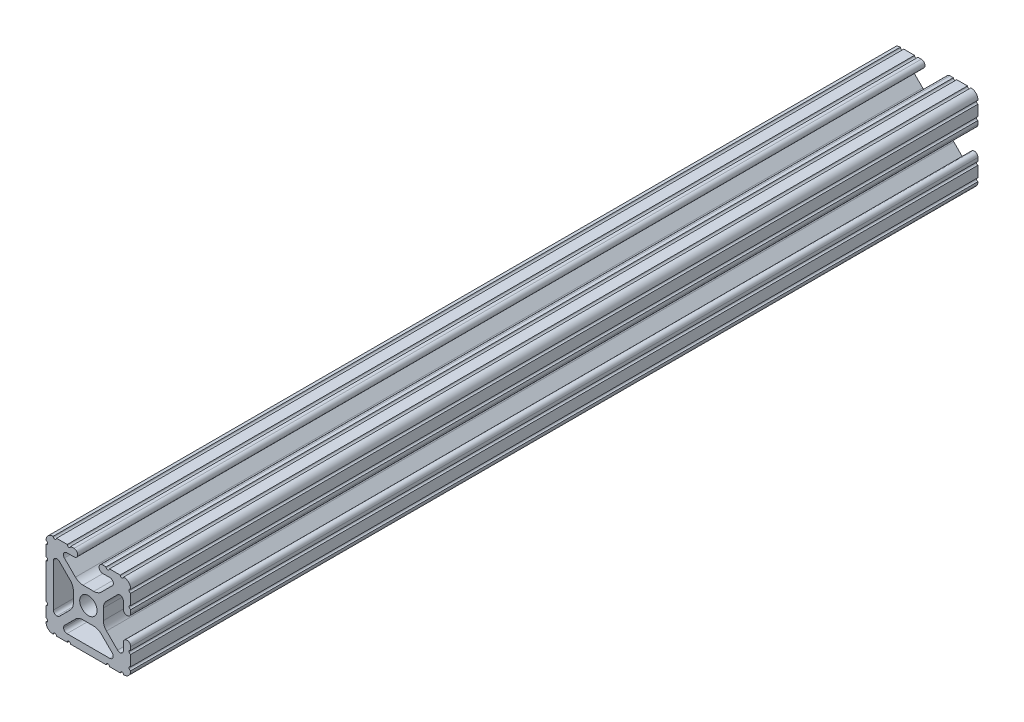
from build123d import *

# Parameters (mm, degrees)
SKETCH1_R           = 2.6035
BOSS_EXTRUDE1_DEPTH = 254


with BuildPart() as part:
    # Sketch1 → Boss-Extrude1 (new body)
    with BuildSketch(Plane(origin=(0, 0, -558.8), x_dir=(-1, 0, 0), z_dir=(0, 0, -1))):
        with BuildLine():
            Line((12.699999967, -9.5504), (12.699999967, -6.3246))
            ThreePointArc((12.699999967, -6.3246), (12.191999967, -5.8166), (12.699999967, -5.3086))
            Line((12.699999967, -5.3086), (12.699999967, 5.3086))
            ThreePointArc((12.699999967, 5.3086), (12.191999967, 5.8166), (12.699999967, 6.3246))
            Line((12.699999967, 6.3246), (12.699999967, 9.550399967))
            ThreePointArc((12.699999967, 9.550399967), (12.191999934, 10.058400016), (12.699999999, 10.566400033))
            ThreePointArc((12.699999999, 10.566400033), (12.082677404, 12.082677438), (10.566399999, 12.700000033))
            ThreePointArc((10.566399999, 12.700000033), (10.058400007, 12.192000016), (9.550399999, 12.700000016))
            Line((9.550399999, 12.700000016), (6.324599999, 12.700000016))
            ThreePointArc((6.324599999, 12.700000016), (5.816599999, 12.192000016), (5.308599999, 12.700000016))
            Line((5.308599999, 12.700000016), (4.302307888, 12.700000016))
            ThreePointArc((4.302307888, 12.700000016), (3.197407888, 11.595100016), (4.302307888, 10.490200016))
            Line((4.302307888, 10.490200016), (6.474794464, 10.490200016))
            ThreePointArc((6.474794464, 10.490200016), (7.413456072, 9.863006381), (7.193214956, 8.755779521))
            Line((7.193214956, 8.755779521), (3.875871421, 5.438435986))
            ThreePointArc((3.875871421, 5.438435986), (2.845827288, 4.7501825), (1.63080739, 4.508500016))
            Line((1.63080739, 4.508500016), (-1.630807376, 4.508500016))
            ThreePointArc((-1.630807376, 4.508500016), (-2.845827273, 4.7501825), (-3.875871406, 5.438435986))
            Line((-3.875871406, 5.438435986), (-7.193214947, 8.755779526))
            ThreePointArc((-7.193214947, 8.755779526), (-7.413456062, 9.863006383), (-6.474794457, 10.490200016))
            Line((-6.474794457, 10.490200016), (-4.302307919, 10.490200016))
            ThreePointArc((-4.302307919, 10.490200016), (-3.197407919, 11.595100016), (-4.302307919, 12.700000016))
            Line((-4.302307919, 12.700000016), (-5.308600001, 12.700000016))
            ThreePointArc((-5.308600001, 12.700000016), (-5.816600001, 12.192000016), (-6.324600001, 12.700000016))
            Line((-6.324600001, 12.700000016), (-9.550400001, 12.700000016))
            ThreePointArc((-9.550400001, 12.700000016), (-10.058400001, 12.192000016), (-10.566400001, 12.700000016))
            ThreePointArc((-10.566400001, 12.700000016), (-12.082677418, 12.082677417), (-12.700000017, 10.5664))
            ThreePointArc((-12.700000017, 10.5664), (-12.192, 10.058400008), (-12.7, 9.5504))
            Line((-12.7, 9.5504), (-12.7, 6.3246))
            ThreePointArc((-12.7, 6.3246), (-12.192, 5.8166), (-12.7, 5.3086))
            Line((-12.7, 5.3086), (-12.7, 4.302307889))
            ThreePointArc((-12.7, 4.302307889), (-11.5951, 3.197407889), (-10.4902, 4.302307889))
            Line((-10.4902, 4.302307889), (-10.4902, 6.474794456))
            ThreePointArc((-10.4902, 6.474794456), (-9.863006367, 7.413456061), (-8.75577951, 7.193214945))
            Line((-8.75577951, 7.193214945), (-5.43843597, 3.875871405))
            ThreePointArc((-5.43843597, 3.875871405), (-4.750182484, 2.845827272), (-4.5085, 1.630807374))
            Line((-4.5085, 1.630807374), (-4.5085, -1.630807374))
            ThreePointArc((-4.5085, -1.630807374), (-4.750182484, -2.845827272), (-5.43843597, -3.875871405))
            Line((-5.43843597, -3.875871405), (-8.75577951, -7.193214945))
            ThreePointArc((-8.75577951, -7.193214945), (-9.863006367, -7.413456061), (-10.4902, -6.474794456))
            Line((-10.4902, -6.474794456), (-10.4902, -4.302307918))
            ThreePointArc((-10.4902, -4.302307918), (-11.5951, -3.197407918), (-12.7, -4.302307918))
            Line((-12.7, -4.302307918), (-12.7, -5.3086))
            ThreePointArc((-12.7, -5.3086), (-12.192, -5.8166), (-12.7, -6.3246))
            Line((-12.7, -6.3246), (-12.7, -9.5504))
            ThreePointArc((-12.7, -9.5504), (-12.192, -10.058400008), (-12.700000017, -10.5664))
            ThreePointArc((-12.700000017, -10.5664), (-12.082677422, -12.082677406), (-10.566400017, -12.7))
            ThreePointArc((-10.566400017, -12.7), (-10.058400017, -12.192), (-9.550400017, -12.7))
            Line((-9.550400017, -12.7), (-6.324600017, -12.7))
            ThreePointArc((-6.324600017, -12.7), (-5.816600017, -12.192), (-5.308600017, -12.7))
            Line((-5.308600017, -12.7), (5.308599983, -12.7))
            ThreePointArc((5.308599983, -12.7), (5.816599983, -12.192), (6.324599983, -12.7))
            Line((6.324599983, -12.7), (9.550399983, -12.7))
            ThreePointArc((9.550399983, -12.7), (10.058399983, -12.192), (10.566399983, -12.7))
            ThreePointArc((10.566399983, -12.7), (12.082677389, -12.082677406), (12.699999983, -10.5664))
            ThreePointArc((12.699999983, -10.5664), (12.191999967, -10.058400008), (12.699999967, -9.5504))
        make_face()
        Circle(SKETCH1_R, mode=Mode.SUBTRACT)
        with BuildLine():
            Line((3.875871405, -5.43843597), (7.13192049, -8.694485055))
            ThreePointArc((7.13192049, -8.694485055), (7.35441848, -9.056211656), (7.4295, -9.4742))
            ThreePointArc((7.4295, -9.4742), (7.13192049, -10.19262049), (6.4135, -10.4902))
            Line((6.4135, -10.4902), (-6.4135, -10.4902))
            ThreePointArc((-6.4135, -10.4902), (-7.13192049, -10.19262049), (-7.4295, -9.4742))
            ThreePointArc((-7.4295, -9.4742), (-7.35441848, -9.056211656), (-7.13192049, -8.694485055))
            Line((-7.13192049, -8.694485055), (-3.875871405, -5.43843597))
            ThreePointArc((-3.875871405, -5.43843597), (-2.845827272, -4.750182484), (-1.630807374, -4.5085))
            Line((-1.630807374, -4.5085), (1.630807374, -4.5085))
            ThreePointArc((1.630807374, -4.5085), (2.845827272, -4.750182484), (3.875871405, -5.43843597))
        make_face(mode=Mode.SUBTRACT)
        with BuildLine():
            Line((10.490199999, 6.4135), (10.490199999, -6.413499984))
            ThreePointArc((10.490199999, -6.413499984), (10.192620488, -7.131920474), (9.474199999, -7.429499984))
            ThreePointArc((9.474199999, -7.429499984), (9.056211655, -7.354418464), (8.694485053, -7.131920474))
            Line((8.694485053, -7.131920474), (5.438435968, -3.875871389))
            ThreePointArc((5.438435968, -3.875871389), (4.750182483, -2.845827256), (4.508499999, -1.630807359))
            Line((4.508499999, -1.630807359), (4.508499999, 1.630807373))
            ThreePointArc((4.508499999, 1.630807373), (4.750182483, 2.845827271), (5.438435968, 3.875871403))
            Line((5.438435968, 3.875871403), (8.694485055, 7.13192049))
            ThreePointArc((8.694485055, 7.13192049), (9.056211656, 7.35441848), (9.4742, 7.4295))
            ThreePointArc((9.4742, 7.4295), (10.192620489, 7.131920489), (10.490199999, 6.4135))
        make_face(mode=Mode.SUBTRACT)
    extrude(amount=-BOSS_EXTRUDE1_DEPTH)


solid = part.part
